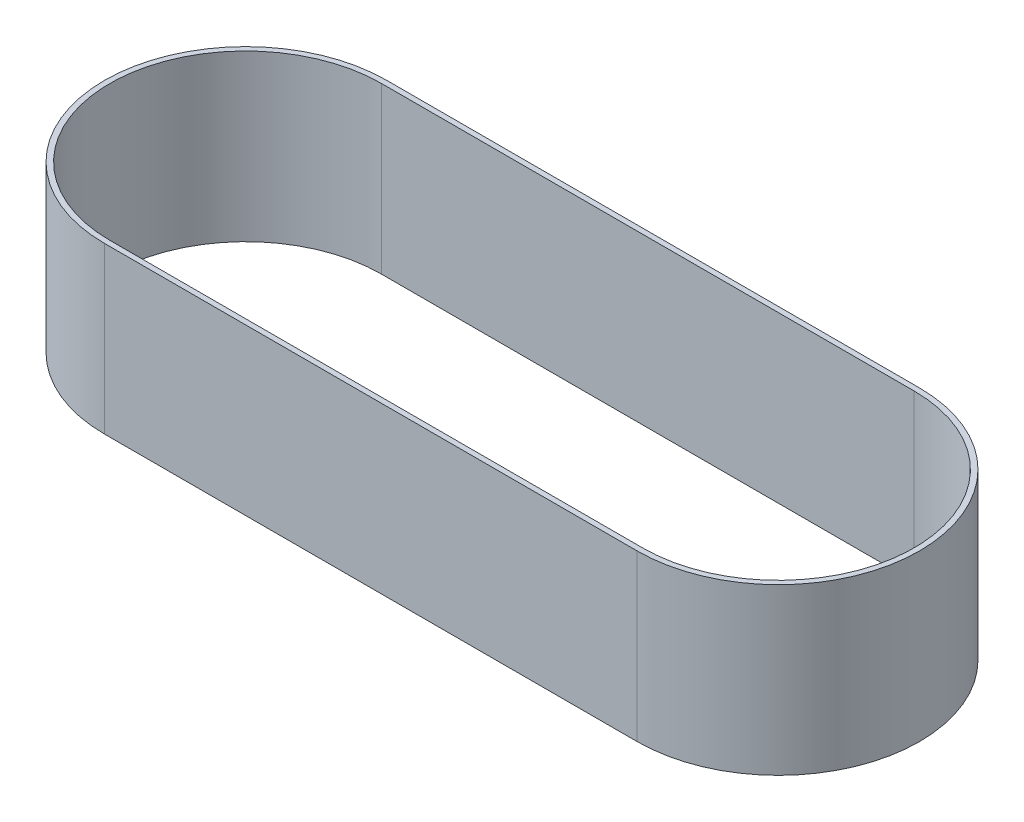
from build123d import *

# Parameters (mm, degrees)
BOSS_EXTRUDE1_DEPTH = 62


with BuildPart() as part:
    # Sketch1 → Boss-Extrude1 (new body)
    with BuildSketch(Plane(origin=(0, 0, 0), x_dir=(1, 0, 0), z_dir=(0, 1, 0))):
        with BuildLine():
            Line((-100, -53), (100, -53))
            ThreePointArc((100, -53), (153, 0), (100, 53))
            Line((100, 53), (-100, 53))
            ThreePointArc((-100, 53), (-153, 0), (-100, -53))
        make_face()
        with BuildLine():
            Line((-100, 51), (100, 51))
            ThreePointArc((100, 51), (151, 0), (100, -51))
            Line((100, -51), (-100, -51))
            ThreePointArc((-100, -51), (-151, 0), (-100, 51))
        make_face(mode=Mode.SUBTRACT)
    extrude(amount=BOSS_EXTRUDE1_DEPTH)


solid = part.part
